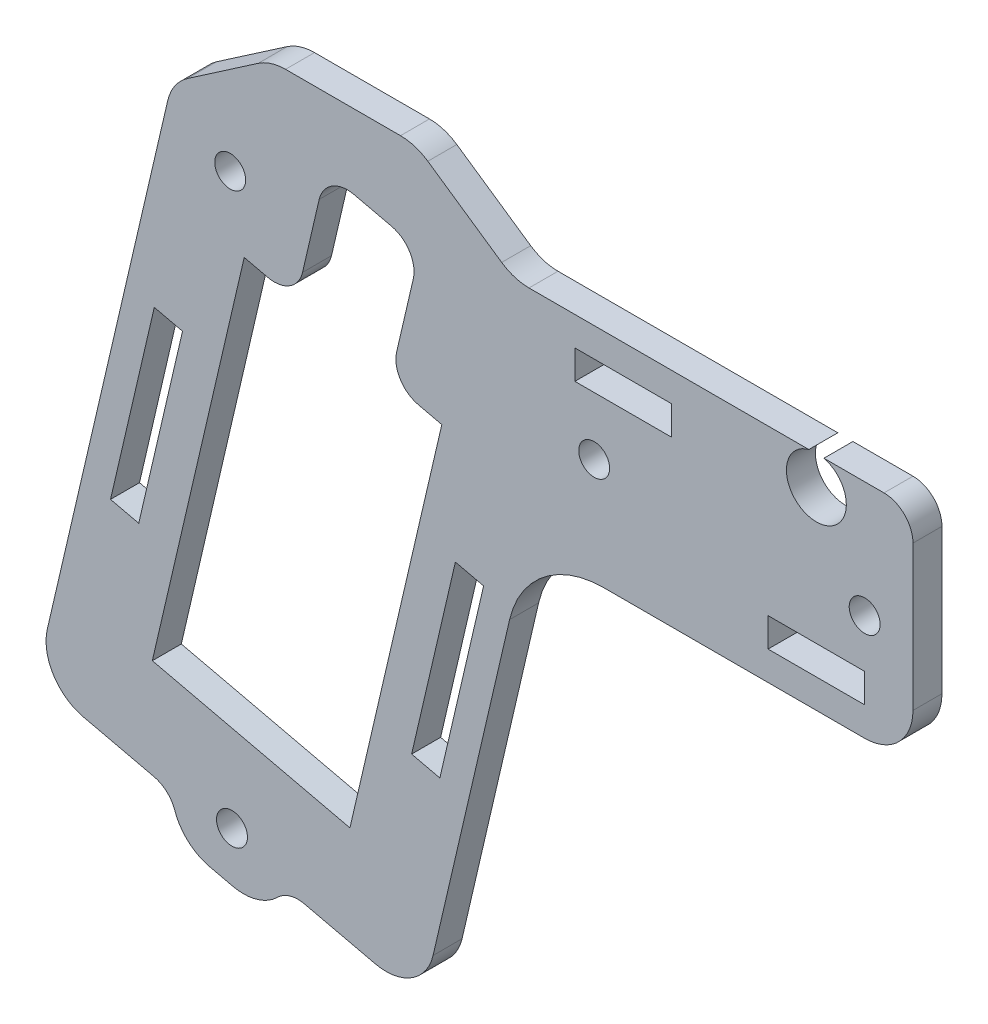
from build123d import *

# Parameters (mm, degrees)
ESBO_O1_R                = 1.6
ESBO_O1_W                = 10
ESBO_O1_H                = 3
RESSALTO_EXTRUS_O1_DEPTH = 3
FILETE1_R                = 5
FILETE3_R                = 3
FILETE4_R                = 10
FILETE2_R                = 5


with BuildPart() as part:
    # Esboço1 → Ressalto-extrusão1 (new body)
    with BuildSketch(Plane.XY):
        with BuildLine():
            Line((-0.781024968, 23), (-31.296028058, 23))
            Line((-31.296028058, 23), (-41.498532893, 30))
            Line((-41.498532893, 30), (-56.498532893, 30))
            Line((-56.498532893, 30), (-66.701037728, 23))
            Line((-66.701037728, 23), (-80.742879141, -37.388961655))
            Line((-80.742879141, -37.388961655), (-65.645638728, -40.899422008))
            Line((-65.645638728, -40.899422008), (-66.494943652, -44.551980173))
            Line((-66.494943652, -44.551980173), (-56.754788546, -46.816793304))
            Line((-56.754788546, -46.816793304), (-55.905483622, -43.164235139))
            Line((-55.905483622, -43.164235139), (-40.808243208, -46.674695492))
            Line((-40.808243208, -46.674695492), (-29.955288394, 0))
            Line((-29.955288394, 0), (10, 0))
            Line((10, 0), (10, 23))
            Line((10, 23), (0.781024968, 23))
            ThreePointArc((0.781024968, 23), (0, 16.9), (-0.781024968, 23))
        make_face()
        with Locations((-60.492459533, -40.814309185)):
            Circle(ESBO_O1_R, mode=Mode.SUBTRACT)
        Polygon((-34.444555902, -6.06061562), (-38.974182165, -25.540925831), (-41.896228696, -24.861481892), (-37.366602434, -5.381171681), align=None, mode=Mode.SUBTRACT)
        Polygon((-70.142678503, -18.293523812), (-73.064725034, -17.614079872), (-68.535098772, 1.866230339), (-65.61305224, 1.1867864), align=None, mode=Mode.SUBTRACT)
        Polygon((-53.868610446, 9.749384541), (-50.787533444, 23), (-41.047378339, 20.735186869), (-44.12845534, 7.48457141), (-38.771370032, 6.238924188), (-48.283585183, -34.669727256), (-68.737910905, -29.91361968), (-59.225695754, 10.995031763), align=None, mode=Mode.SUBTRACT)
        with Locations((-60.676910422, 18)):
            Circle(ESBO_O1_R, mode=Mode.SUBTRACT)
        with Locations((0, 4.5)):
            Rectangle(ESBO_O1_W, ESBO_O1_H, mode=Mode.SUBTRACT)
        with Locations((-23, 11)):
            Circle(ESBO_O1_R, mode=Mode.SUBTRACT)
        with Locations((-20, 18.5)):
            Rectangle(ESBO_O1_W, ESBO_O1_H, mode=Mode.SUBTRACT)
        with Locations((5, 11)):
            Circle(ESBO_O1_R, mode=Mode.SUBTRACT)
    extrude(amount=RESSALTO_EXTRUS_O1_DEPTH)

    # Filete1
    filete1_edges = [part.edges().sort_by_distance(p)[0] for p in [
        (10, 0, 1.5),
        (-40.808243208, -46.674695492, 1.5),
        (-80.742879141, -37.388961655, 1.5),
    ]]
    fillet(filete1_edges, radius=FILETE1_R)

    # Filete3
    filete3_edges = [part.edges().sort_by_distance(p)[0] for p in [
        (10, 23, 1.5),
        (-55.905483622, -43.164235139, 1.5),
        (-65.645638728, -40.899422008, 1.5),
        (-53.868610446, 9.749384541, 1.5),
        (-44.12845534, 7.48457141, 1.5),
        (-41.047378339, 20.735186869, 1.5),
        (-50.787533444, 23, 1.5),
    ]]
    fillet(filete3_edges, radius=FILETE3_R)

    # Filete4
    filete4_edges = [part.edges().sort_by_distance(p)[0] for p in [
        (-29.955288394, 0, 1.5),
    ]]
    fillet(filete4_edges, radius=FILETE4_R)

    # Filete2
    filete2_edges = [part.edges().sort_by_distance(p)[0] for p in [
        (-56.754788546, -46.816793304, 1.5),
        (-66.494943652, -44.551980173, 1.5),
        (-31.296028058, 23, 1.5),
        (-41.498532893, 30, 1.5),
        (-56.498532893, 30, 1.5),
        (-66.701037728, 23, 1.5),
    ]]
    fillet(filete2_edges, radius=FILETE2_R)


solid = part.part
